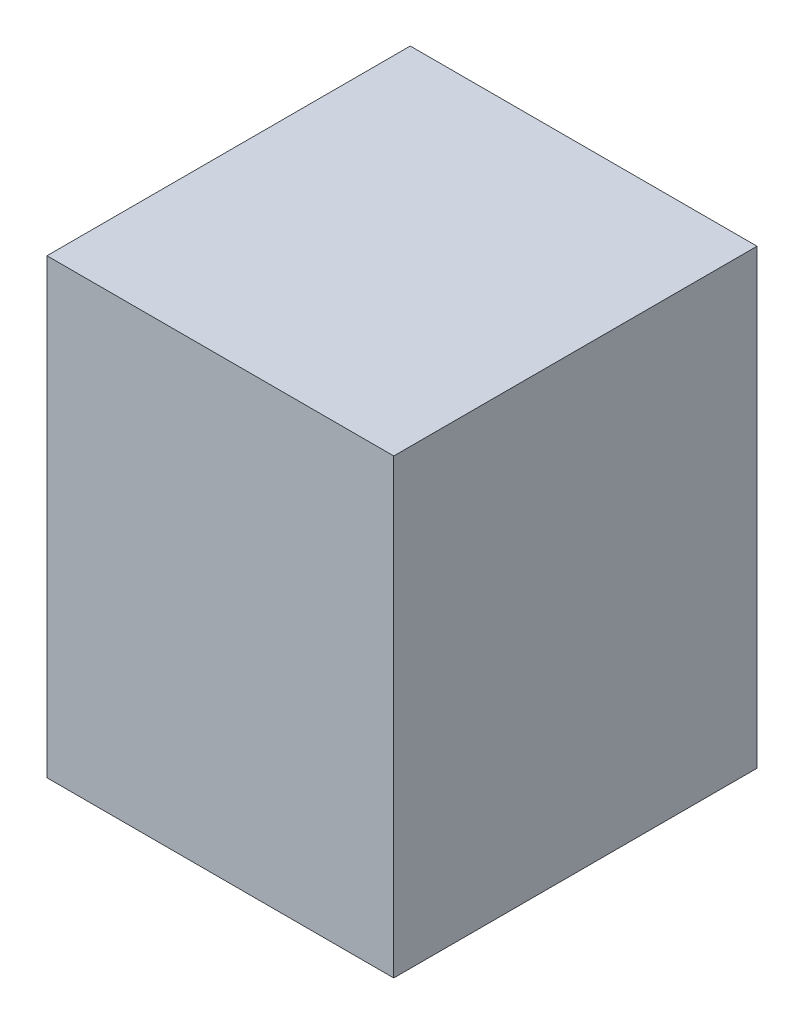
from build123d import *

# Parameters (mm, degrees)
SKETCH1_W           = 439.1
SKETCH1_H           = 572.45
SKETCH1_W_2         = 419.1
SKETCH1_H_2         = 552.45
BOSS_EXTRUDE1_DEPTH = 450
SKETCH3_W           = 439.1
SKETCH3_H           = 572.45
BOSS_EXTRUDE2_DEPTH = 10


with BuildPart() as part:
    # Sketch1 → Boss-Extrude1 (new body)
    with BuildSketch(Plane.XY):
        with Locations((209.55, 276.225)):
            Rectangle(SKETCH1_W, SKETCH1_H)
        with Locations((209.55, 276.225)):
            Rectangle(SKETCH1_W_2, SKETCH1_H_2, mode=Mode.SUBTRACT)
    extrude(amount=BOSS_EXTRUDE1_DEPTH)

    # Sketch3 → Boss-Extrude2 (add)
    with BuildSketch(Plane.XY.offset(450)):
        with Locations((209.55, 276.225)):
            Rectangle(SKETCH3_W, SKETCH3_H)
    extrude(amount=BOSS_EXTRUDE2_DEPTH)


solid = part.part
